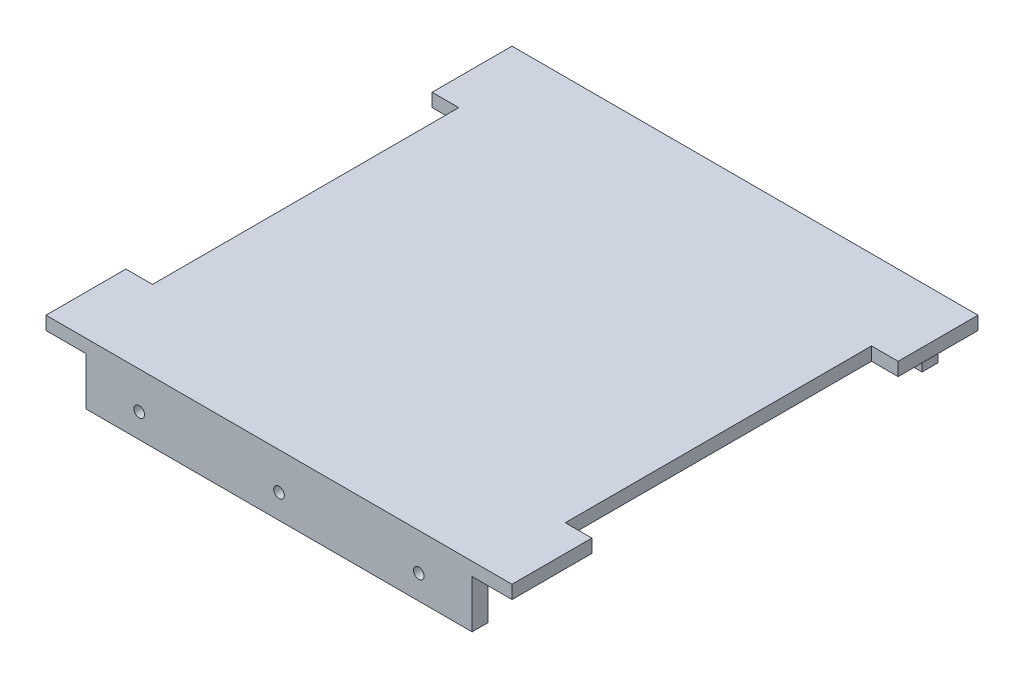
from build123d import *

# Parameters (mm, degrees)
SKETCH1_W               = 175
SKETCH1_H               = 175
BOSS_EXTRUDE1_DEPTH     = 5
SKETCH3_W               = 145
SKETCH3_H               = 6
BOSS_EXTRUDE3_DEPTH     = 18
SKETCH4_R               = 2
CUT_EXTRUDE2_DEPTH      = 1
CUT_EXTRUDE2_DEPTH_BACK = 176
SKETCH5_W               = 10
SKETCH5_H               = 115
CUT_EXTRUDE3_DEPTH      = 10


with BuildPart() as part:
    # Sketch1 → Boss-Extrude1 (new body)
    with BuildSketch(Plane(origin=(0, 0, 0), x_dir=(1, 0, 0), z_dir=(0, 1, 0))):
        with Locations((-24.045801527, -27.385496183)):
            Rectangle(SKETCH1_W, SKETCH1_H)
    extrude(amount=BOSS_EXTRUDE1_DEPTH)

    # Sketch3 → Boss-Extrude3 (add)
    with BuildSketch(Plane.XZ):
        with Locations((-24.045801527, 111.885496183)):
            Rectangle(SKETCH3_W, SKETCH3_H)
        with Locations((-24.045801527, -57.114503817)):
            Rectangle(SKETCH3_W, SKETCH3_H)
    extrude(amount=BOSS_EXTRUDE3_DEPTH)

    # Sketch4 → Cut-Extrude2 (cut, two sides)
    with BuildSketch(Plane(origin=(0, 0, -60.114503817), x_dir=(-1, 0, 0), z_dir=(0, 0, -1))) as cut_extrude2_sk:
        with Locations((-28.454198473, -8.900832872)):
            Circle(SKETCH4_R)
        with Locations((24.045801527, -8.900832872)):
            Circle(SKETCH4_R)
        with Locations((76.545801527, -8.900832872)):
            Circle(SKETCH4_R)
    extrude(amount=CUT_EXTRUDE2_DEPTH, mode=Mode.SUBTRACT)
    extrude(cut_extrude2_sk.sketch, amount=-CUT_EXTRUDE2_DEPTH_BACK, mode=Mode.SUBTRACT)

    # Sketch5 → Cut-Extrude3 (cut)
    with BuildSketch(Plane(origin=(0, 5, 0), x_dir=(1, 0, 0), z_dir=(0, 1, 0))):
        with Locations((-106.545801527, -27.385496183)):
            Rectangle(SKETCH5_W, SKETCH5_H)
        with Locations((58.454198473, -27.385496183)):
            Rectangle(SKETCH5_W, SKETCH5_H)
    extrude(amount=-CUT_EXTRUDE3_DEPTH, mode=Mode.SUBTRACT)


solid = part.part
